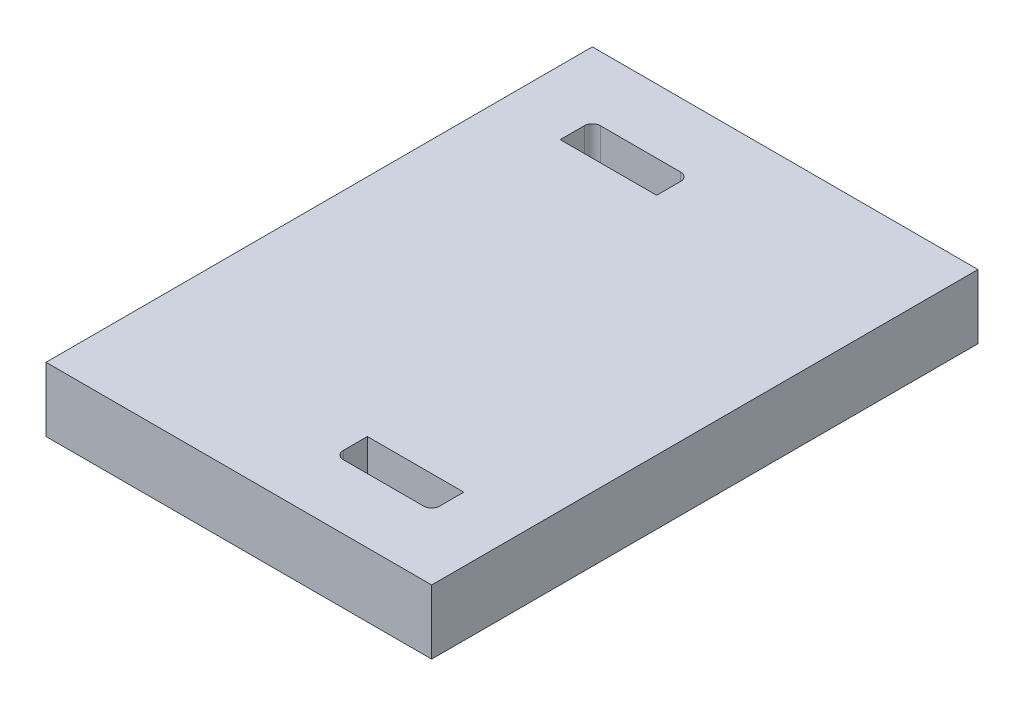
from build123d import *

# Parameters (mm, degrees)
SKIZZE1_W                       = 12
SKIZZE1_H                       = 17
AUFSATZ_LINEAR_AUSTRAGEN1_DEPTH = 2
SKIZZE3_W                       = 3
SKIZZE3_H                       = 1
SCHNITT_LINEAR_AUSTRAGEN1_DEPTH = 3
VERRUNDUNG1_R                   = 0.25


with BuildPart() as part:
    # Skizze1 → Aufsatz-Linear austragen1 (new body)
    with BuildSketch(Plane(origin=(0, 0, 0), x_dir=(1, 0, 0), z_dir=(0, 1, 0))):
        with Locations((6, 8.5)):
            Rectangle(SKIZZE1_W, SKIZZE1_H)
    extrude(amount=AUFSATZ_LINEAR_AUSTRAGEN1_DEPTH)

    # Skizze3 → Schnitt-Linear austragen1 (cut, through all)
    with BuildSketch(Plane(origin=(0, 2, 0), x_dir=(1, 0, 0), z_dir=(0, 1, 0))):
        with Locations((8.5, 2.5)):
            Rectangle(SKIZZE3_W, SKIZZE3_H)
        with Locations((3.5, 14.5)):
            Rectangle(SKIZZE3_W, SKIZZE3_H)
    extrude(amount=-SCHNITT_LINEAR_AUSTRAGEN1_DEPTH, mode=Mode.SUBTRACT)

    # Verrundung1
    verrundung1_edges = [part.edges().sort_by_distance(p)[0] for p in [
        (7, 1, -2),
        (10, 1, -2),
        (2, 1, -15),
        (5, 1, -15),
    ]]
    fillet(verrundung1_edges, radius=VERRUNDUNG1_R)


solid = part.part
